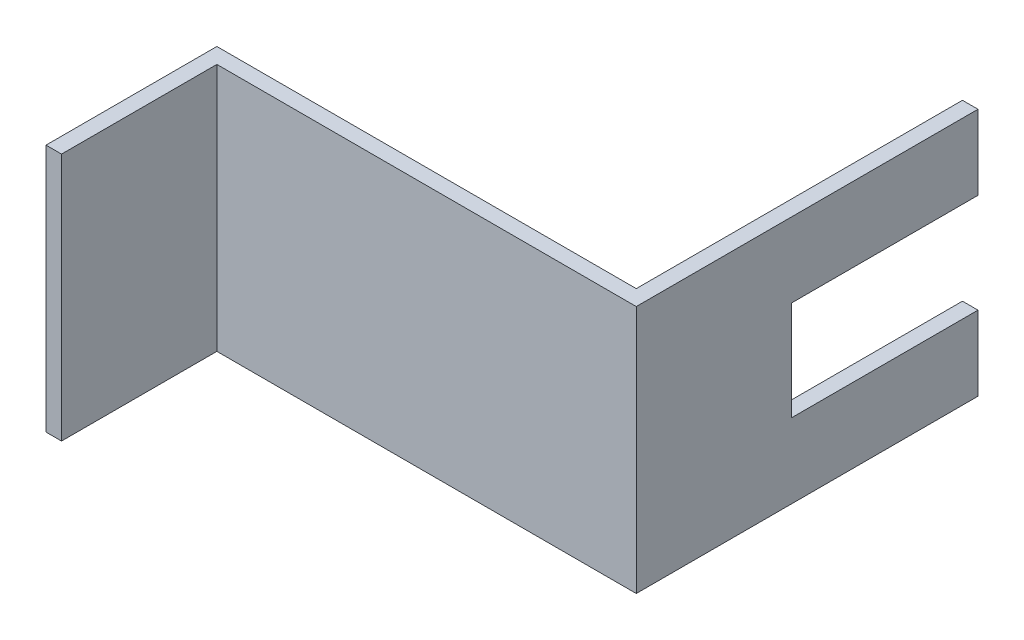
from build123d import *

# Parameters (mm, degrees)
SKETCH1_W           = 41.275
SKETCH1_H           = 1.5875
BOSS_EXTRUDE1_DEPTH = 25.4
SKETCH2_W           = 19.05
SKETCH2_H           = 10.16
CUT_EXTRUDE1_DEPTH  = 25.4


with BuildPart() as part:
    # Sketch1 → Boss-Extrude1 (new body)
    with BuildSketch(Plane(origin=(0, 0, 0), x_dir=(1, 0, 0), z_dir=(0, 1, 0))):
        Polygon((-13.211086677, -8.065885175), (-13.211086677, -6.478385175), (-14.798586677, -6.478385175), (-14.798586677, -23.940885175), (-13.211086677, -23.940885175), align=None)
        with Locations((7.426413323, -7.272135175)):
            Rectangle(SKETCH1_W, SKETCH1_H)
        Polygon((29.651413323, 26.859114825), (28.063913323, 26.859114825), (28.063913323, -6.478385175), (28.063913323, -8.065885175), (29.651413323, -8.065885175), align=None)
    extrude(amount=BOSS_EXTRUDE1_DEPTH)

    # Sketch2 → Cut-Extrude1 (cut)
    with BuildSketch(Plane(origin=(29.651413323, 0, 0), x_dir=(0, 0, -1), z_dir=(1, 0, 0))):
        with Locations((17.334114825, 12.7)):
            Rectangle(SKETCH2_W, SKETCH2_H)
    extrude(amount=-CUT_EXTRUDE1_DEPTH, mode=Mode.SUBTRACT)


solid = part.part
